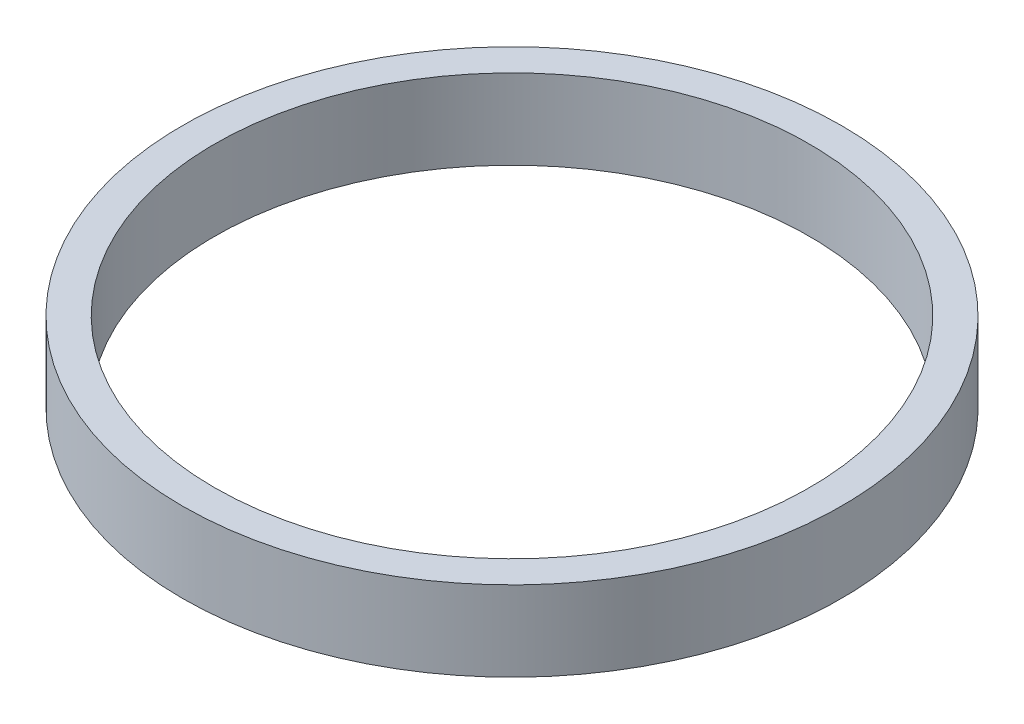
from build123d import *

# Parameters (mm, degrees)
ESQUISSE1_R        = 20.6
ESQUISSE1_R_2      = 18.6
BOSS_EXTRU_1_DEPTH = 5


with BuildPart() as part:
    # Esquisse1 → Boss.-Extru.1 (new body)
    with BuildSketch(Plane(origin=(0, 0, 0), x_dir=(1, 0, 0), z_dir=(0, 1, 0))):
        Circle(ESQUISSE1_R)
        Circle(ESQUISSE1_R_2, mode=Mode.SUBTRACT)
    extrude(amount=BOSS_EXTRU_1_DEPTH)


solid = part.part
